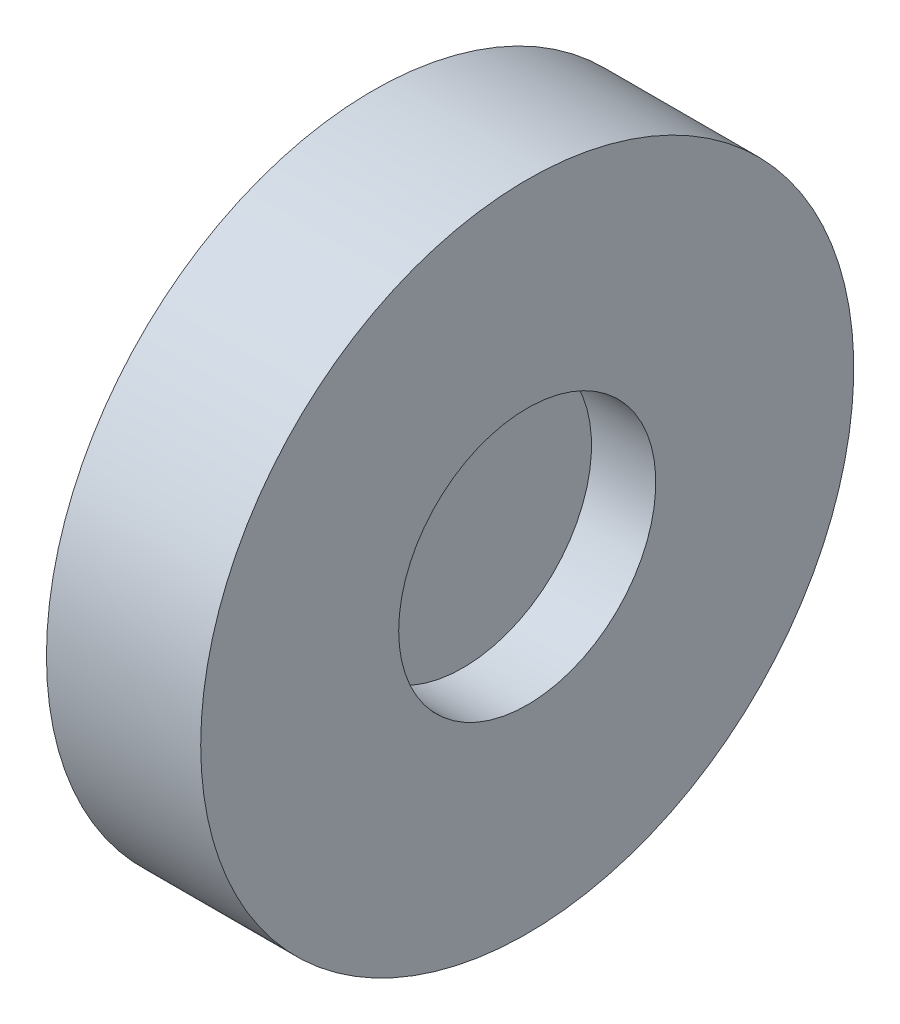
from build123d import *

# Parameters (mm, degrees)
SKETCH_1_W = 1
SKETCH_1_H = 5
SKETCH_4_W = 6
SKETCH_4_H = 7.7


with BuildPart() as part:
    # 草图1 → 旋转2 (revolve)
    with BuildSketch(Plane.XY, mode=Mode.PRIVATE) as revolve_2_sk:
        with Locations((0, 2.5)):
            Rectangle(SKETCH_1_W, SKETCH_1_H)
    revolve(revolve_2_sk.sketch.rotate(Axis((-0.5, 0, 0), (1, 0, 0)), 90), axis=Axis((-0.5, 0, 0), (1, 0, 0)))  # turned: the seam where the file's is

    # 草图4 → 旋转3 (revolve)
    with BuildSketch(Plane.XY, mode=Mode.PRIVATE) as revolve_3_sk:
        with Locations((0, 8.85)):
            Rectangle(SKETCH_4_W, SKETCH_4_H)
    revolve(revolve_3_sk.sketch.rotate(Axis((-1.614212419, 0, 0), (1, 0, 0)), 90), axis=Axis((-1.614212419, 0, 0), (1, 0, 0)))  # turned: the seam where the file's is


solid = part.part
